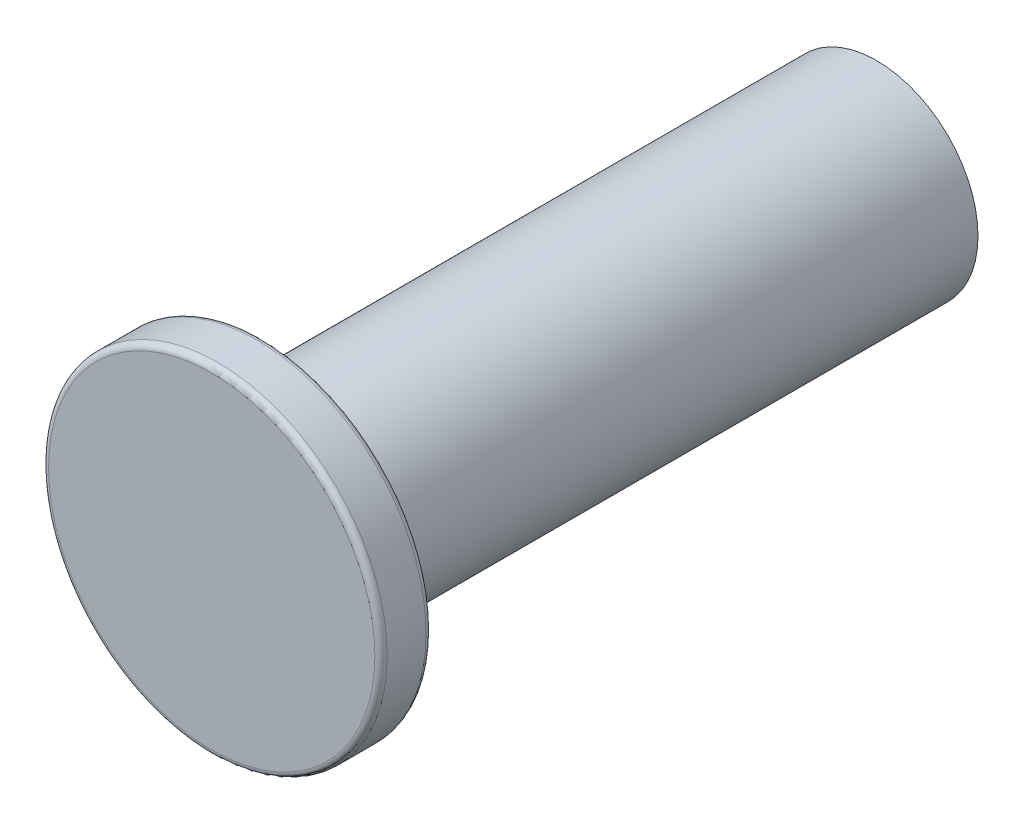
from build123d import *

# Parameters (mm, degrees)
SKETCH1_R           = 12.573
BOSS_EXTRUDE1_DEPTH = 76.2
SKETCH2_R           = 21.0185
BOSS_EXTRUDE2_DEPTH = 6.35
FILLET1_R           = 0.762


with BuildPart() as part:
    # Sketch1 → Boss-Extrude1 (new body)
    with BuildSketch(Plane.XY):
        Circle(SKETCH1_R)
    extrude(amount=-BOSS_EXTRUDE1_DEPTH)

    # Sketch2 → Boss-Extrude2 (add)
    with BuildSketch(Plane.XY):
        Circle(SKETCH2_R)
    extrude(amount=BOSS_EXTRUDE2_DEPTH)

    # Fillet1
    fillet1_edges = [part.edges().sort_by_distance(p)[0] for p in [
        (-21.0185, 0, 0),
        (-21.0185, 0, 6.35),
    ]]
    fillet(fillet1_edges, radius=FILLET1_R)


solid = part.part
